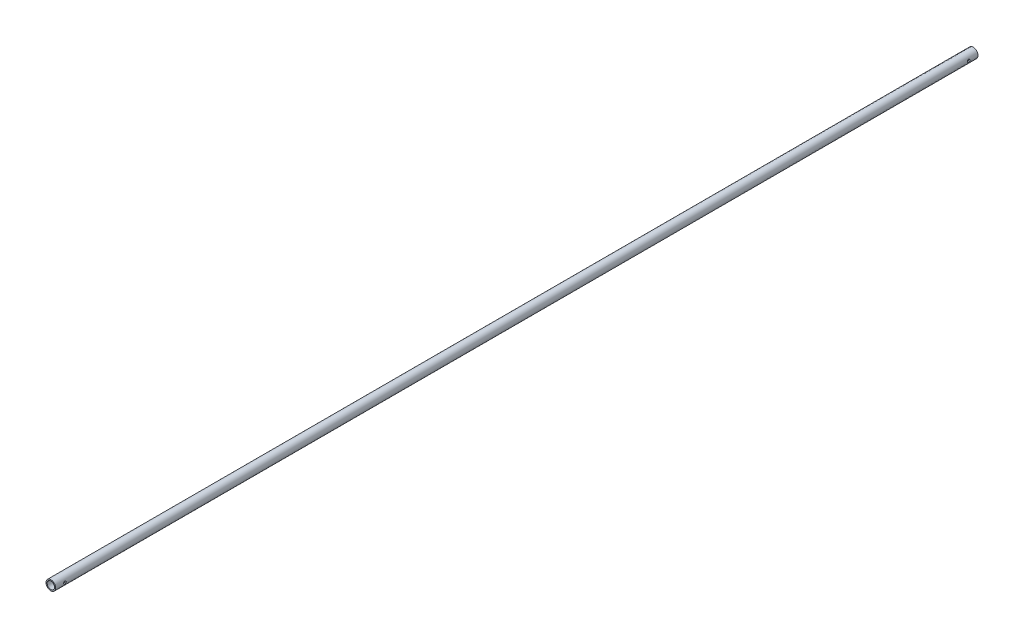
from build123d import *

# Parameters (mm, degrees)
CROQUIS1_R                   = 12.5
CROQUIS1_R_2                 = 9.5
SALIENTE_EXTRUIR1_DEPTH      = 2380
SALIENTE_EXTRUIR1_DEPTH_BACK = 3
CROQUIS2_R                   = 3.43
CORTAR_EXTRUIR1_DEPTH        = 13.5
CORTAR_EXTRUIR1_DEPTH_BACK   = 13.5
CROQUIS3_R                   = 3.43
CORTAR_EXTRUIR2_DEPTH        = 13.5000001
CORTAR_EXTRUIR2_DEPTH_BACK   = 13.5000001


with BuildPart() as part:
    # Croquis1 → Saliente-Extruir1 (new body, two sides)
    with BuildSketch(Plane.XY) as saliente_extruir1_sk:
        Circle(CROQUIS1_R)
        Circle(CROQUIS1_R_2, mode=Mode.SUBTRACT)
    extrude(amount=SALIENTE_EXTRUIR1_DEPTH)
    extrude(saliente_extruir1_sk.sketch, amount=-SALIENTE_EXTRUIR1_DEPTH_BACK)

    # Croquis2 → Cortar-Extruir1 (cut, two sides)
    with BuildSketch(Plane(origin=(0, 0, 0), x_dir=(0, 0, -1), z_dir=(1, 0, 0))) as cortar_extruir1_sk:
        with Locations((-21, 0)):
            Circle(CROQUIS2_R)
    extrude(amount=CORTAR_EXTRUIR1_DEPTH, mode=Mode.SUBTRACT)
    extrude(cortar_extruir1_sk.sketch, amount=-CORTAR_EXTRUIR1_DEPTH_BACK, mode=Mode.SUBTRACT)

    # Croquis3 → Cortar-Extruir2 (cut, two sides)
    with BuildSketch(Plane(origin=(0, 0, 0), x_dir=(0, 0, -1), z_dir=(1, 0, 0))) as cortar_extruir2_sk:
        with Locations((-2356, 0)):
            Circle(CROQUIS3_R)
    extrude(amount=CORTAR_EXTRUIR2_DEPTH, mode=Mode.SUBTRACT)
    extrude(cortar_extruir2_sk.sketch, amount=-CORTAR_EXTRUIR2_DEPTH_BACK, mode=Mode.SUBTRACT)


solid = part.part
